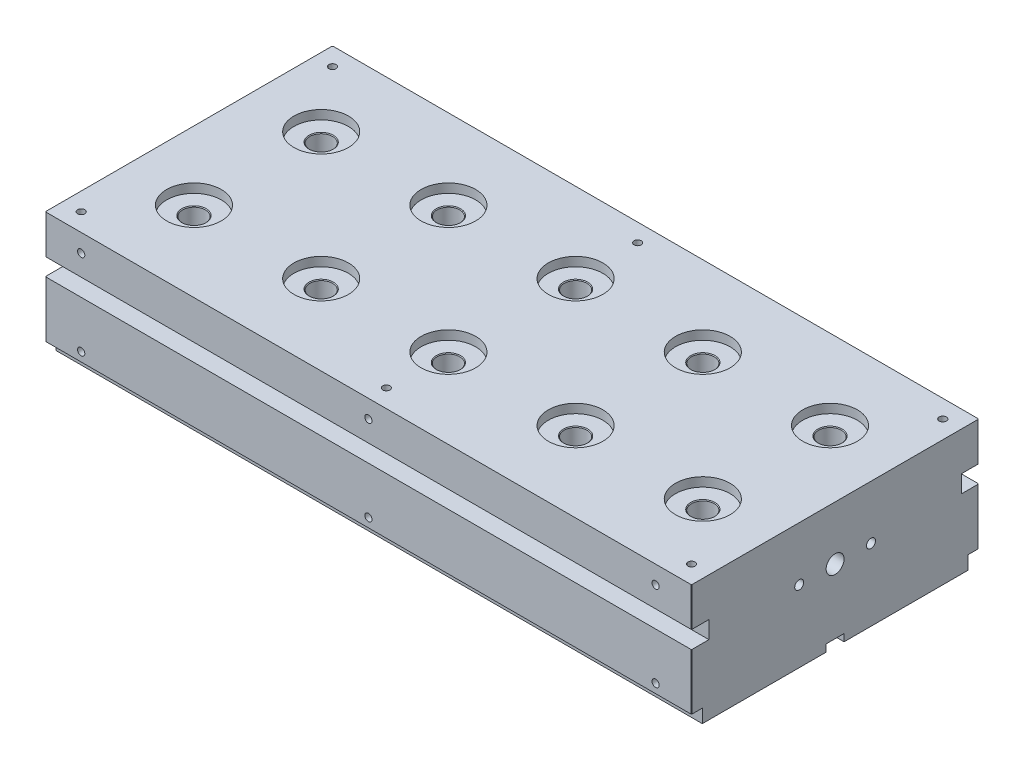
from build123d import *

# Parameters (mm, degrees)
SKETCH2_W                        = 457.2
SKETCH2_H                        = 203.2
BOSS_EXTRUDE1_DEPTH              = 101.6
F_97_0_0059_DIAMETER_HOLE1_D     = 16.129
F_97_0_0059_DIAMETER_HOLE1_DEPTH = 101.6
SKETCH6_R                        = 19.304
CUT_EXTRUDE1_DEPTH               = 19.1
SKETCH7_R                        = 6.35
CUT_EXTRUDE2_DEPTH               = 458.2
CUT_EXTRUDE3_DEPTH               = 458.2
F_4_40_TAPPED_HOLE1_AT_2_COUNT   = 2
F_4_40_TAPPED_HOLE1_AT_2_PITCH   = 142.24
F_4_40_TAPPED_HOLE1_AT_3_COUNT   = 2
F_4_40_TAPPED_HOLE1_AT_3_PITCH   = 284.48
F_4_40_TAPPED_HOLE1_AT_4_COUNT   = 2
F_4_40_TAPPED_HOLE1_AT_4_PITCH   = 426.72
SKETCH13_W                       = 497.107303422
SKETCH13_H                       = 12.7
CUT_EXTRUDE4_DEPTH               = 5.08
F_10_32_TAPPED_HOLE1_D           = 4.0386
F_10_32_TAPPED_HOLE1_DEPTH       = 13.716
F_10_32_TAPPED_HOLE1_CSINK_D     = 5.2578
F_10_32_TAPPED_HOLE1_CSINK_ANGLE = 90
F_10_32_TAPPED_HOLE1_TIP         = 1.213317848
CHAMFER1_SIZE                    = 0.508
CUT_EXTRUDE5_DEPTH               = 1
CUT_EXTRUDE5_DEPTH_BACK          = 458.2
F_1_4_20_TAPPED_HOLE1_D          = 5.1054
F_1_4_20_TAPPED_HOLE1_DEPTH      = 14.976183098
F_1_4_20_TAPPED_HOLE1_TIP        = 1.533816902
F_1_4_20_TAPPED_HOLE2_AT_2_COUNT = 2
F_1_4_20_TAPPED_HOLE2_AT_2_PITCH = 203.2
F_1_4_20_TAPPED_HOLE2_AT_3_COUNT = 2
F_1_4_20_TAPPED_HOLE2_AT_3_PITCH = 406.4
F_1_4_20_TAPPED_HOLE2_AT_4_COUNT = 2
F_1_4_20_TAPPED_HOLE2_AT_4_PITCH = 410.852851548
F_1_4_20_TAPPED_HOLE2_AT_5_COUNT = 2
F_1_4_20_TAPPED_HOLE2_AT_5_PITCH = 211.965434977
F_1_4_20_TAPPED_HOLE2_AT_6_COUNT = 2
F_1_4_20_TAPPED_HOLE2_AT_6_PITCH = 60.325
F_1_4_0_25_DIAMETER_HOLE1_D      = 6.35
F_1_4_0_25_DIAMETER_HOLE1_DEPTH  = 35.56
F_1_4_0_25_DIAMETER_HOLE1_TIP    = 1.907732465


with BuildPart() as part:
    # Sketch2 → Boss-Extrude1 (new body)
    with BuildSketch(Plane(origin=(0, 0, 0), x_dir=(1, 0, 0), z_dir=(0, 1, 0))):
        Rectangle(SKETCH2_W, SKETCH2_H)
    extrude(amount=-BOSS_EXTRUDE1_DEPTH)

    # #97 (0.0059) Diameter Hole1
    with Locations(Plane(origin=(0, 0, 0), x_dir=(1, 0, 0), z_dir=(0, 1, 0))):
        with Locations((-180, 45), (-180, -45), (-90, -45), (-90, 45), (0, 45), (0, -45), (90, 45), (90, -45), (180, 45), (180, -45)):
            Hole(F_97_0_0059_DIAMETER_HOLE1_D / 2, depth=F_97_0_0059_DIAMETER_HOLE1_DEPTH)

    # Sketch6 → Cut-Extrude1 (cut)
    with BuildSketch(Plane(origin=(0, 0, 0), x_dir=(1, 0, 0), z_dir=(0, 1, 0))):
        with Locations((-180, 45)):
            Circle(SKETCH6_R)
        with Locations((-90, 45)):
            Circle(SKETCH6_R)
        with Locations((0, 45)):
            Circle(SKETCH6_R)
        with Locations((90, 45)):
            Circle(SKETCH6_R)
        with Locations((180, 45)):
            Circle(SKETCH6_R)
        with Locations((-180, -45)):
            Circle(SKETCH6_R)
        with Locations((-90, -45)):
            Circle(SKETCH6_R)
        with Locations((0, -45)):
            Circle(SKETCH6_R)
        with Locations((90, -45)):
            Circle(SKETCH6_R)
        with Locations((180, -45)):
            Circle(SKETCH6_R)
    extrude(amount=-CUT_EXTRUDE1_DEPTH, mode=Mode.SUBTRACT)

    # Sketch7 → Cut-Extrude2 (cut, through all)
    with BuildSketch(Plane(origin=(228.6, 0, 0), x_dir=(0, 0, -1), z_dir=(1, 0, 0))):
        with Locations((0, -50.8)):
            Circle(SKETCH7_R)
    extrude(amount=-CUT_EXTRUDE2_DEPTH, mode=Mode.SUBTRACT)

    # Sketch9 → Cut-Extrude3 (cut, through all)
    with BuildSketch(Plane(origin=(228.6, 0, 0), x_dir=(0, 0, -1), z_dir=(1, 0, 0))):
        Polygon((-125.631572208, -92.075), (-93.96, -92.075), (-93.96, -105.632755967), (93.96, -105.632755967), (93.96, -92.075), (107.488435479, -92.075), (107.488435479, -145.314266525), (-125.631572208, -145.314266525), align=None)
    extrude(amount=-CUT_EXTRUDE3_DEPTH, mode=Mode.SUBTRACT)

    # Sketch12 → #4-40 Tapped Hole1 (revolve, cut)
    with BuildSketch(Plane(origin=(-213.36, -96.8375, 93.96), x_dir=(0, -1, 0), z_dir=(1, 0, 0))):
        Polygon((0, 0), (0, 9.569152758), (1.1303, 8.89), (1.1303, 0.5461), (1.6764, 0), align=None)
    f_4_40_tapped_hole1 = revolve(axis=Axis((-213.36, -96.8375, 100.31), (0, 0, -1)), mode=Mode.SUBTRACT)

    # #4-40 Tapped Hole1 at 2: #4-40 Tapped Hole1 ×2
    with Locations(*[(i * F_4_40_TAPPED_HOLE1_AT_2_PITCH, 0, 0) for i in range(1, F_4_40_TAPPED_HOLE1_AT_2_COUNT)]):
        add(f_4_40_tapped_hole1, mode=Mode.SUBTRACT)

    # #4-40 Tapped Hole1 at 3: #4-40 Tapped Hole1 ×2
    with Locations(*[(i * F_4_40_TAPPED_HOLE1_AT_3_PITCH, 0, 0) for i in range(1, F_4_40_TAPPED_HOLE1_AT_3_COUNT)]):
        add(f_4_40_tapped_hole1, mode=Mode.SUBTRACT)

    # #4-40 Tapped Hole1 at 4: #4-40 Tapped Hole1 ×2
    with Locations(*[(i * F_4_40_TAPPED_HOLE1_AT_4_PITCH, 0, 0) for i in range(1, F_4_40_TAPPED_HOLE1_AT_4_COUNT)]):
        add(f_4_40_tapped_hole1, mode=Mode.SUBTRACT)

    # Mirror1: #4-40 Tapped Hole1 across plane
    add(f_4_40_tapped_hole1.mirror(Plane.XY), mode=Mode.SUBTRACT)

    # Mirror1 copy 1 sketch → Mirror1 copy 1 (revolve, cut)
    with BuildSketch(Plane(origin=(-71.12, -96.8375, -93.96), x_dir=(0, -1, 0), z_dir=(1, 0, 0))):
        Polygon((0, 0), (0, -9.569152758), (1.1303, -8.89), (1.1303, -0.5461), (1.6764, 0), align=None)
    revolve(axis=Axis((-71.12, -96.8375, -100.31), (0, 0, -1)), mode=Mode.SUBTRACT)

    # Mirror1 copy 2 sketch → Mirror1 copy 2 (revolve, cut)
    with BuildSketch(Plane(origin=(71.12, -96.8375, -93.96), x_dir=(0, -1, 0), z_dir=(1, 0, 0))):
        Polygon((0, 0), (0, -9.569152758), (1.1303, -8.89), (1.1303, -0.5461), (1.6764, 0), align=None)
    revolve(axis=Axis((71.12, -96.8375, -100.31), (0, 0, -1)), mode=Mode.SUBTRACT)

    # Mirror1 copy 3 sketch → Mirror1 copy 3 (revolve, cut)
    with BuildSketch(Plane(origin=(213.36, -96.8375, -93.96), x_dir=(0, -1, 0), z_dir=(1, 0, 0))):
        Polygon((0, 0), (0, -9.569152758), (1.1303, -8.89), (1.1303, -0.5461), (1.6764, 0), align=None)
    revolve(axis=Axis((213.36, -96.8375, -100.31), (0, 0, -1)), mode=Mode.SUBTRACT)

    # Sketch13 → Cut-Extrude4 (cut)
    with BuildSketch(Plane.XZ.offset(101.6)):
        with Locations((-10.232623869, 0)):
            Rectangle(SKETCH13_W, SKETCH13_H)
    extrude(amount=-CUT_EXTRUDE4_DEPTH, mode=Mode.SUBTRACT)

    # #10-32 Tapped Hole1
    with Locations(Plane(origin=(0, -96.52, 0), x_dir=(-1, 0, 0), z_dir=(0, -1, 0))):
        with Locations((0, 0)):
            CounterSinkHole(F_10_32_TAPPED_HOLE1_D / 2, F_10_32_TAPPED_HOLE1_CSINK_D / 2, depth=F_10_32_TAPPED_HOLE1_DEPTH, counter_sink_angle=F_10_32_TAPPED_HOLE1_CSINK_ANGLE)
            with Locations((0, 0, -(F_10_32_TAPPED_HOLE1_DEPTH + F_10_32_TAPPED_HOLE1_TIP / 2))):  # 118° drill point
                Cone(0, F_10_32_TAPPED_HOLE1_D / 2, F_10_32_TAPPED_HOLE1_TIP, mode=Mode.SUBTRACT)

    # Chamfer1
    chamfer1_edges = [part.edges().sort_by_distance(p)[0] for p in [
        (-81.9355, -19.1, -45),
        (-109.304, 0, -45),
        (8.0645, -19.1, -45),
        (-19.304, 0, -45),
        (98.0645, -19.1, -45),
        (70.696, 0, -45),
        (188.0645, -19.1, -45),
        (160.696, 0, -45),
        (-171.9355, -19.1, 45),
        (-199.304, 0, 45),
        (-81.9355, -19.1, 45),
        (-109.304, 0, 45),
        (8.0645, -19.1, 45),
        (-19.304, 0, 45),
        (98.0645, -19.1, 45),
        (70.696, 0, 45),
        (188.0645, -19.1, 45),
        (160.696, 0, 45),
        (-171.9355, -19.1, -45),
        (-199.304, 0, -45),
        (-228.6, -46.0375, 101.6),
        (228.6, -46.0375, 101.6),
        (228.6, -46.0375, -101.6),
        (-228.6, -46.0375, -101.6),
        (0, 0, -101.6),
        (228.6, 0, 0),
        (0, 0, 101.6),
        (-228.6, 0, 0),
    ]]
    chamfer(chamfer1_edges, length=CHAMFER1_SIZE)

    # Sketch17 → Cut-Extrude5 (cut, two sides)
    with BuildSketch(Plane.ZY.offset(228.6)) as cut_extrude5_sk:
        Polygon((-127.800683028, -12.7), (122.379768518, -12.7), (122.379768518, -40.132), (89.281, -40.132), (89.281, -52.451), (139.415899373, -52.451), (139.415899373, 38.570613424), (-149.880951183, 38.570613424), (-149.880951183, -52.451), (-89.281, -52.451), (-89.281, -40.132), (-127.800683028, -40.132), align=None)
    extrude(amount=CUT_EXTRUDE5_DEPTH, mode=Mode.SUBTRACT)
    extrude(cut_extrude5_sk.sketch, amount=-CUT_EXTRUDE5_DEPTH_BACK, mode=Mode.SUBTRACT)

    # 1/4-20 Tapped Hole1
    with Locations(Plane(origin=(0, -12.7, 0), x_dir=(1, 0, 0), z_dir=(0, 1, 0))):
        with Locations((-215.9, 88.9), (0, 88.9), (215.9, 88.9), (215.9, -88.9), (0, -88.9), (-215.9, -88.9)):
            Hole(F_1_4_20_TAPPED_HOLE1_D / 2, depth=F_1_4_20_TAPPED_HOLE1_DEPTH)
            with Locations((0, 0, -(F_1_4_20_TAPPED_HOLE1_DEPTH + F_1_4_20_TAPPED_HOLE1_TIP / 2))):  # 118° drill point
                Cone(0, F_1_4_20_TAPPED_HOLE1_D / 2, F_1_4_20_TAPPED_HOLE1_TIP, mode=Mode.SUBTRACT)

    # Sketch23 → 1/4-20 Tapped Hole2 (revolve, cut)
    with BuildSketch(Plane(origin=(-203.2, -25.4, 101.6), x_dir=(0, -1, 0), z_dir=(1, 0, 0))):
        Polygon((0, 0), (0, 16.51), (2.5527, 14.976183098), (2.5527, 0), align=None)
    f_1_4_20_tapped_hole2 = revolve(axis=Axis((-203.2, -25.4, 107.95), (0, 0, -1)), mode=Mode.SUBTRACT)

    # 1/4-20 Tapped Hole2 at 2: 1/4-20 Tapped Hole2 ×2
    with Locations(*[(i * F_1_4_20_TAPPED_HOLE2_AT_2_PITCH, 0, 0) for i in range(1, F_1_4_20_TAPPED_HOLE2_AT_2_COUNT)]):
        add(f_1_4_20_tapped_hole2, mode=Mode.SUBTRACT)

    # 1/4-20 Tapped Hole2 at 3: 1/4-20 Tapped Hole2 ×2
    with Locations(*[(i * F_1_4_20_TAPPED_HOLE2_AT_3_PITCH, 0, 0) for i in range(1, F_1_4_20_TAPPED_HOLE2_AT_3_COUNT)]):
        add(f_1_4_20_tapped_hole2, mode=Mode.SUBTRACT)

    # 1/4-20 Tapped Hole2 at 4: 1/4-20 Tapped Hole2 ×2
    with Locations(*[Vector(0.989161931, -0.146828724, 0) * (i * F_1_4_20_TAPPED_HOLE2_AT_4_PITCH) for i in range(1, F_1_4_20_TAPPED_HOLE2_AT_4_COUNT)]):
        add(f_1_4_20_tapped_hole2, mode=Mode.SUBTRACT)

    # 1/4-20 Tapped Hole2 at 5: 1/4-20 Tapped Hole2 ×2
    with Locations(*[Vector(0.958646866, -0.284598288, 0) * (i * F_1_4_20_TAPPED_HOLE2_AT_5_PITCH) for i in range(1, F_1_4_20_TAPPED_HOLE2_AT_5_COUNT)]):
        add(f_1_4_20_tapped_hole2, mode=Mode.SUBTRACT)

    # 1/4-20 Tapped Hole2 at 6: 1/4-20 Tapped Hole2 ×2
    with Locations(*[(0, -i * F_1_4_20_TAPPED_HOLE2_AT_6_PITCH, 0) for i in range(1, F_1_4_20_TAPPED_HOLE2_AT_6_COUNT)]):
        add(f_1_4_20_tapped_hole2, mode=Mode.SUBTRACT)

    # Mirror2: 1/4-20 Tapped Hole2 across plane
    add(f_1_4_20_tapped_hole2.mirror(Plane.XY), mode=Mode.SUBTRACT)

    # Mirror2 copy 1 sketch → Mirror2 copy 1 (revolve, cut)
    with BuildSketch(Plane(origin=(0, -25.4, -101.6), x_dir=(0, -1, 0), z_dir=(1, 0, 0))):
        Polygon((0, 0), (0, -16.51), (2.5527, -14.976183098), (2.5527, 0), align=None)
    revolve(axis=Axis((0, -25.4, -107.95), (0, 0, -1)), mode=Mode.SUBTRACT)

    # Mirror2 copy 2 sketch → Mirror2 copy 2 (revolve, cut)
    with BuildSketch(Plane(origin=(203.2, -25.4, -101.6), x_dir=(0, -1, 0), z_dir=(1, 0, 0))):
        Polygon((0, 0), (0, -16.51), (2.5527, -14.976183098), (2.5527, 0), align=None)
    revolve(axis=Axis((203.2, -25.4, -107.95), (0, 0, -1)), mode=Mode.SUBTRACT)

    # Mirror2 copy 3 sketch → Mirror2 copy 3 (revolve, cut)
    with BuildSketch(Plane(origin=(203.2, -85.725, -101.6), x_dir=(0, -1, 0), z_dir=(1, 0, 0))):
        Polygon((0, 0), (0, -16.51), (2.5527, -14.976183098), (2.5527, 0), align=None)
    revolve(axis=Axis((203.2, -85.725, -107.95), (0, 0, -1)), mode=Mode.SUBTRACT)

    # Mirror2 copy 4 sketch → Mirror2 copy 4 (revolve, cut)
    with BuildSketch(Plane(origin=(0, -85.725, -101.6), x_dir=(0, -1, 0), z_dir=(1, 0, 0))):
        Polygon((0, 0), (0, -16.51), (2.5527, -14.976183098), (2.5527, 0), align=None)
    revolve(axis=Axis((0, -85.725, -107.95), (0, 0, -1)), mode=Mode.SUBTRACT)

    # Mirror2 copy 5 sketch → Mirror2 copy 5 (revolve, cut)
    with BuildSketch(Plane(origin=(-203.2, -85.725, -101.6), x_dir=(0, -1, 0), z_dir=(1, 0, 0))):
        Polygon((0, 0), (0, -16.51), (2.5527, -14.976183098), (2.5527, 0), align=None)
    revolve(axis=Axis((-203.2, -85.725, -107.95), (0, 0, -1)), mode=Mode.SUBTRACT)

    # 1/4 (0.25) Diameter Hole1
    with Locations(Plane(origin=(228.6, 0, 0), x_dir=(0, 0, -1), z_dir=(1, 0, 0))):
        with Locations((-25.4, -50.8), (25.4, -50.8)):
            Hole(F_1_4_0_25_DIAMETER_HOLE1_D / 2, depth=F_1_4_0_25_DIAMETER_HOLE1_DEPTH)
            with Locations((0, 0, -(F_1_4_0_25_DIAMETER_HOLE1_DEPTH + F_1_4_0_25_DIAMETER_HOLE1_TIP / 2))):  # 118° drill point
                Cone(0, F_1_4_0_25_DIAMETER_HOLE1_D / 2, F_1_4_0_25_DIAMETER_HOLE1_TIP, mode=Mode.SUBTRACT)


solid = part.part
